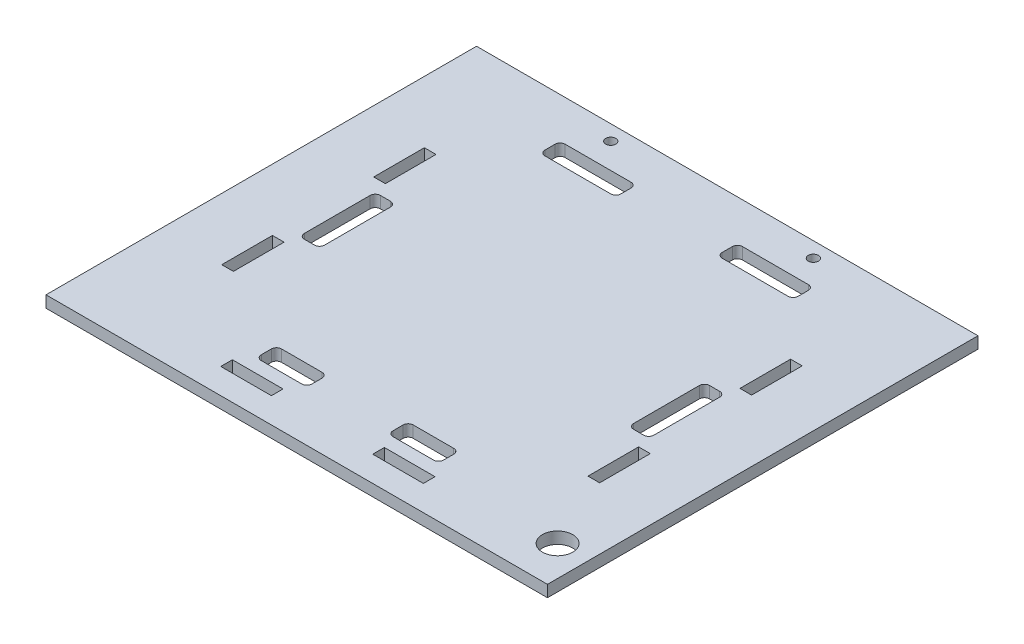
from build123d import *

# Parameters (mm, degrees)
BOSS_EXTRUDE1_DEPTH = 2.3
SKETCH2_R           = 1
CUT_EXTRUDE1_DEPTH  = 2.3
SKETCH3_W           = 10
SKETCH3_H           = 2.3
CUT_EXTRUDE2_DEPTH  = 2.3
SKETCH4_W           = 15
SKETCH4_H           = 4
CUT_EXTRUDE3_DEPTH  = 10
SKETCH5_W           = 2.3
SKETCH5_H           = 10
CUT_EXTRUDE4_DEPTH  = 2.3
FILLET1_R           = 1
SKETCH6_W           = 4
SKETCH6_H           = 15
SKETCH6_W_2         = 10
SKETCH6_H_2         = 4
CUT_EXTRUDE5_DEPTH  = 10
FILLET3_R           = 1
SKETCH7_R           = 3
CUT_EXTRUDE6_DEPTH  = 10


with BuildPart() as part:
    # Sketch1 → Boss-Extrude1 (new body)
    with BuildSketch(Plane(origin=(0, 0, 0), x_dir=(1, 0, 0), z_dir=(0, 1, 0))):
        Polygon((0, -50), (-49.5, -50), (-49.5, 0), (-49.5, 35), (0, 35), (49.5, 35), (49.5, 0), (49.5, -50), align=None)
    extrude(amount=BOSS_EXTRUDE1_DEPTH)

    # Sketch2 → Cut-Extrude1 (cut)
    with BuildSketch(Plane(origin=(0, 2.3, 0), x_dir=(1, 0, 0), z_dir=(0, 1, 0))):
        with Locations((-20, 32)):
            Circle(SKETCH2_R)
        with Locations((20, 32)):
            Circle(SKETCH2_R)
    extrude(amount=-CUT_EXTRUDE1_DEPTH, mode=Mode.SUBTRACT)

    # Sketch3 → Cut-Extrude2 (cut)
    with BuildSketch(Plane(origin=(0, 2.3, 0), x_dir=(1, 0, 0), z_dir=(0, 1, 0))):
        with Locations((-15, -43.85)):
            Rectangle(SKETCH3_W, SKETCH3_H)
        with Locations((15, -43.85)):
            Rectangle(SKETCH3_W, SKETCH3_H)
    extrude(amount=-CUT_EXTRUDE2_DEPTH, mode=Mode.SUBTRACT)

    # Sketch4 → Cut-Extrude3 (cut)
    with BuildSketch(Plane(origin=(0, 2.3, 0), x_dir=(1, 0, 0), z_dir=(0, 1, 0))):
        with Locations((-17.5, 25)):
            Rectangle(SKETCH4_W, SKETCH4_H)
        with Locations((17.5, 25)):
            Rectangle(SKETCH4_W, SKETCH4_H)
    extrude(amount=-CUT_EXTRUDE3_DEPTH, mode=Mode.SUBTRACT)

    # Sketch5 → Cut-Extrude4 (cut)
    with BuildSketch(Plane(origin=(0, 2.3, 0), x_dir=(1, 0, 0), z_dir=(0, 1, 0))):
        with Locations((-36.15, 7.5)):
            Rectangle(SKETCH5_W, SKETCH5_H)
        with Locations((-36.15, -22.5)):
            Rectangle(SKETCH5_W, SKETCH5_H)
        with Locations((36.15, -22.5)):
            Rectangle(SKETCH5_W, SKETCH5_H)
        with Locations((36.15, 7.5)):
            Rectangle(SKETCH5_W, SKETCH5_H)
    extrude(amount=-CUT_EXTRUDE4_DEPTH, mode=Mode.SUBTRACT)

    # Fillet1
    fillet1_edges = [part.edges().sort_by_distance(p)[0] for p in [
        (-25, 1.15, -23),
        (-25, 1.15, -27),
        (-10, 1.15, -27),
        (-10, 1.15, -23),
        (10, 1.15, -23),
        (10, 1.15, -27),
        (25, 1.15, -27),
        (25, 1.15, -23),
    ]]
    fillet(fillet1_edges, radius=FILLET1_R)

    # Sketch6 → Cut-Extrude5 (cut)
    with BuildSketch(Plane(origin=(0, 2.3, 0), x_dir=(1, 0, 0), z_dir=(0, 1, 0))):
        with Locations((32.5, -7.5)):
            Rectangle(SKETCH6_W, SKETCH6_H)
        with Locations((-32.5, -7.5)):
            Rectangle(SKETCH6_W, SKETCH6_H)
        with Locations((-13, -38)):
            Rectangle(SKETCH6_W_2, SKETCH6_H_2)
        with Locations((13, -38)):
            Rectangle(SKETCH6_W_2, SKETCH6_H_2)
    extrude(amount=-CUT_EXTRUDE5_DEPTH, mode=Mode.SUBTRACT)

    # Fillet3
    fillet3_edges = [part.edges().sort_by_distance(p)[0] for p in [
        (-34.5, 1.15, 15),
        (-34.5, 1.15, 0),
        (-30.5, 1.15, 0),
        (-30.5, 1.15, 15),
        (34.5, 1.15, 15),
        (30.5, 1.15, 15),
        (30.5, 1.15, 0),
        (34.5, 1.15, 0),
        (-8, 1.15, 36),
        (-8, 1.15, 40),
        (-18, 1.15, 40),
        (-18, 1.15, 36),
        (8, 1.15, 40),
        (8, 1.15, 36),
        (18, 1.15, 36),
        (18, 1.15, 40),
    ]]
    fillet(fillet3_edges, radius=FILLET3_R)

    # Sketch7 → Cut-Extrude6 (cut)
    with BuildSketch(Plane(origin=(0, 2.3, 0), x_dir=(1, 0, 0), z_dir=(0, 1, 0))):
        with Locations((43.5, -42)):
            Circle(SKETCH7_R)
    extrude(amount=-CUT_EXTRUDE6_DEPTH, mode=Mode.SUBTRACT)


solid = part.part
